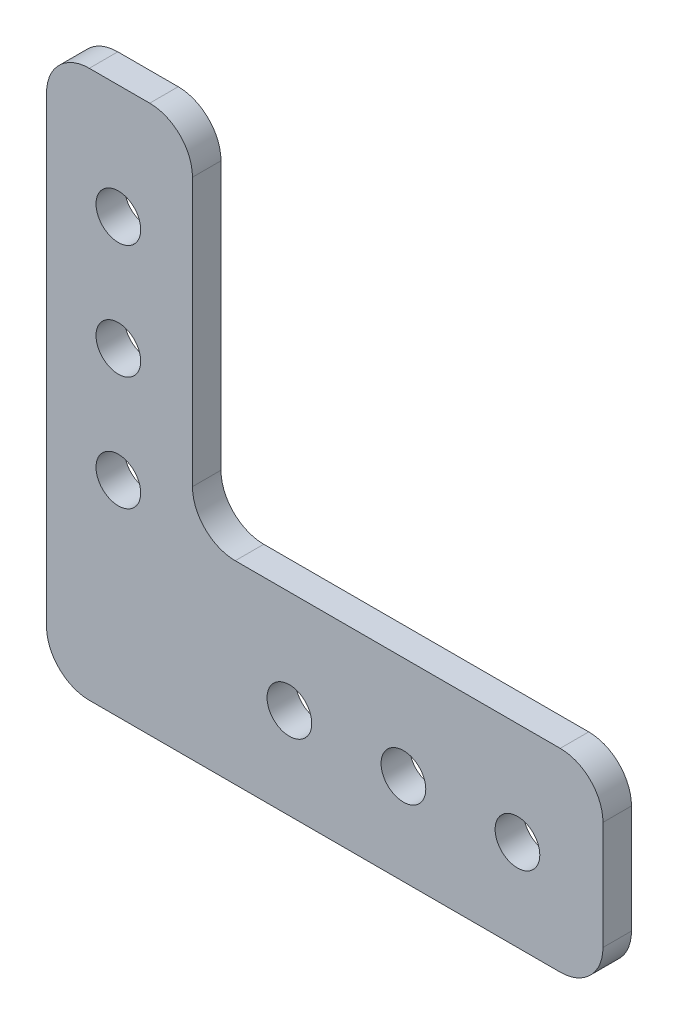
from build123d import *

# Parameters (mm, degrees)
SKETCH1_R           = 2.4892
BOSS_EXTRUDE1_DEPTH = 3.175
FILLET1_R           = 4.7625


with BuildPart() as part:
    # Sketch1 → Boss-Extrude1 (new body)
    with BuildSketch(Plane.XY):
        Polygon((-27.051, 31.75), (-27.051, -29.21), (34.925, -29.21), (34.925, -7.62), (-10.795, -7.62), (-10.795, 31.75), align=None)
        with Locations((-19.05, -19.05)):
            Circle(SKETCH1_R, mode=Mode.SUBTRACT)
        with Locations((-19.05, -6.35)):
            Circle(SKETCH1_R, mode=Mode.SUBTRACT)
        with Locations((0, -19.05)):
            Circle(SKETCH1_R, mode=Mode.SUBTRACT)
        with Locations((12.7, -19.05)):
            Circle(SKETCH1_R, mode=Mode.SUBTRACT)
        with Locations((25.4, -19.05)):
            Circle(SKETCH1_R, mode=Mode.SUBTRACT)
        with Locations((-19.05, 6.35)):
            Circle(SKETCH1_R, mode=Mode.SUBTRACT)
        with Locations((-19.05, 19.05)):
            Circle(SKETCH1_R, mode=Mode.SUBTRACT)
        with Locations((-19.05, -19.05)):
            Circle(SKETCH1_R)
    extrude(amount=BOSS_EXTRUDE1_DEPTH)

    # Fillet1
    fillet1_edges = [part.edges().sort_by_distance(p)[0] for p in [
        (-27.051, 31.75, 1.5875),
        (-10.795, 31.75, 1.5875),
        (-10.795, -7.62, 1.5875),
        (34.925, -7.62, 1.5875),
        (34.925, -29.21, 1.5875),
        (-27.051, -29.21, 1.5875),
    ]]
    fillet(fillet1_edges, radius=FILLET1_R)


solid = part.part
